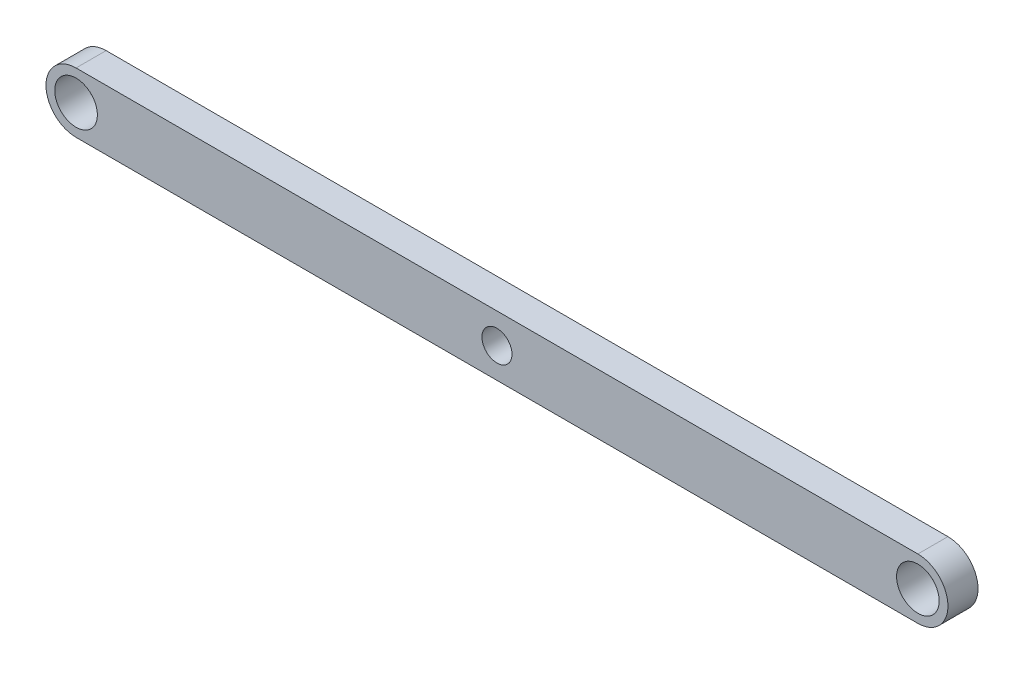
from build123d import *

# Parameters (mm, degrees)
SKETCH1_R           = 4.5
SKETCH1_R_2         = 3.175
BOSS_EXTRUDE1_DEPTH = 6.35


with BuildPart() as part:
    # Sketch1 → Boss-Extrude1 (new body)
    with BuildSketch(Plane.XY):
        with BuildLine():
            Line((-88.9, 6.35), (88.9, 6.35))
            ThreePointArc((88.9, 6.35), (95.25, 0), (88.9, -6.35))
            Line((88.9, -6.35), (-88.9, -6.35))
            ThreePointArc((-88.9, -6.35), (-95.25, 0), (-88.9, 6.35))
        make_face()
        with Locations((-88.9, 0)):
            Circle(SKETCH1_R, mode=Mode.SUBTRACT)
        with Locations((88.9, 0)):
            Circle(SKETCH1_R, mode=Mode.SUBTRACT)
        Circle(SKETCH1_R_2, mode=Mode.SUBTRACT)
    extrude(amount=BOSS_EXTRUDE1_DEPTH)


solid = part.part
